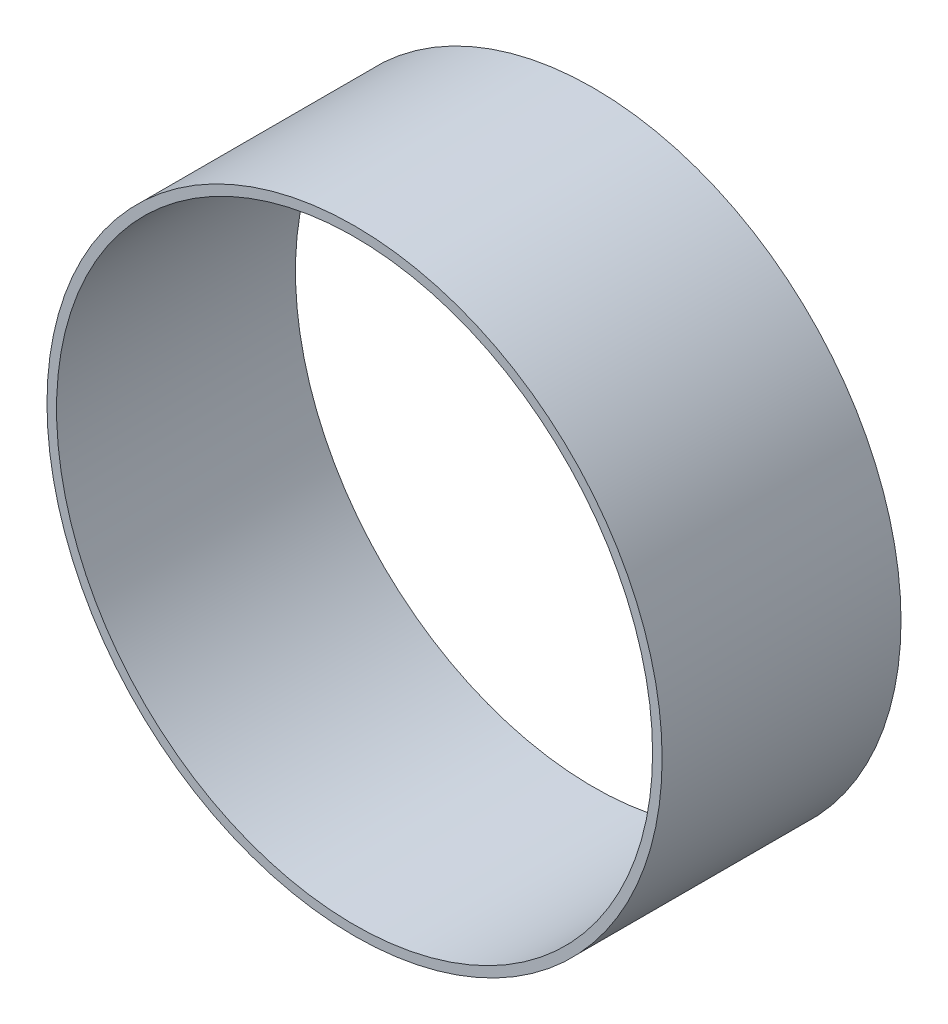
from build123d import *

# Parameters (mm, degrees)
SKETCH1_R           = 65.405
SKETCH1_R_2         = 63.373
BOSS_EXTRUDE1_DEPTH = 25.4


with BuildPart() as part:
    # Sketch1 → Boss-Extrude1 (new body, symmetric)
    with BuildSketch(Plane.XY):
        Circle(SKETCH1_R)
        Circle(SKETCH1_R_2, mode=Mode.SUBTRACT)
    extrude(amount=BOSS_EXTRUDE1_DEPTH, both=True)


solid = part.part
